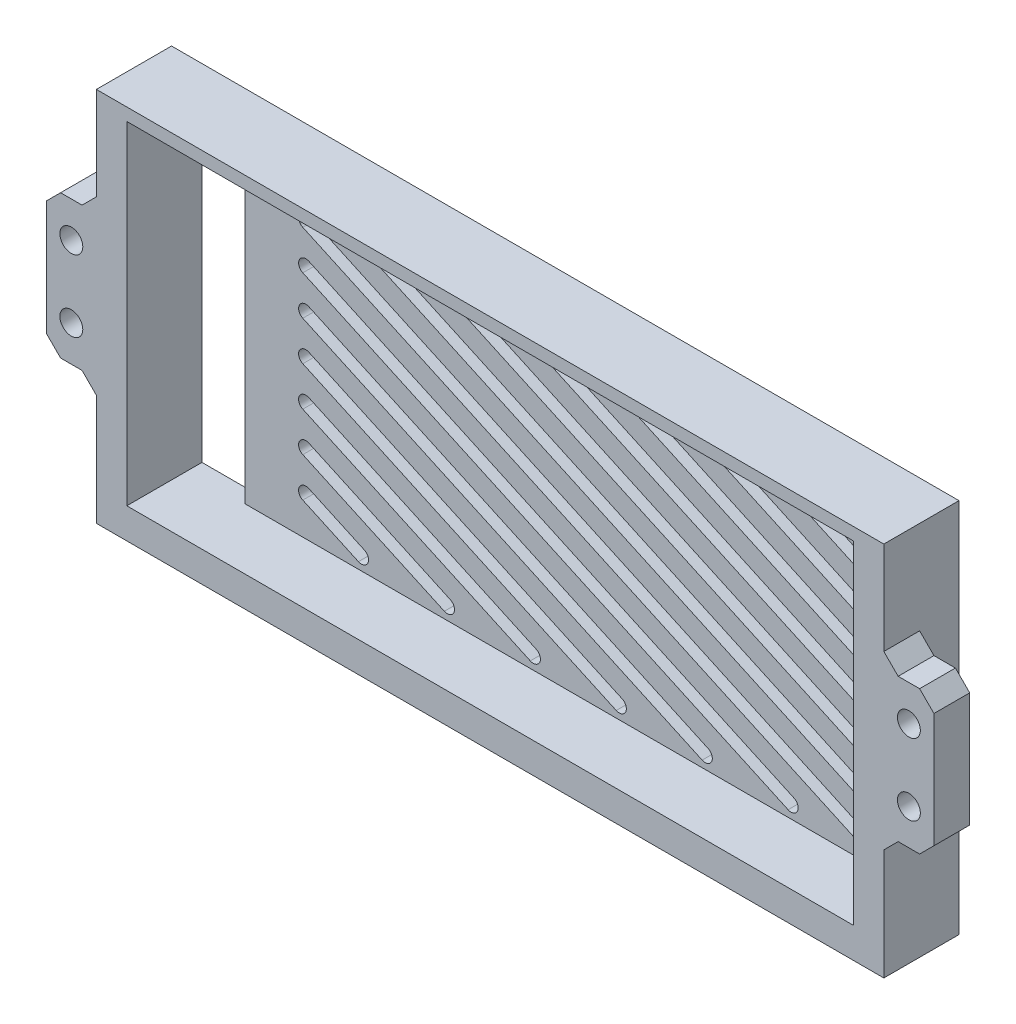
from build123d import *

# Parameters (mm, degrees)
SKETCH_1_W          = 110
SKETCH_1_H          = 52.5
EXTRUDE_1_DEPTH     = 2
SKETCH_2_W          = 110
SKETCH_2_H          = 52.5
SKETCH_2_W_2        = 101.5
SKETCH_2_H_2        = 46.5
EXTRUDE_2_DEPTH     = 8.5
CUT_EXTRUDE_1_DEPTH = 3
SKETCH_5_W          = 8
SKETCH_5_H          = 46.5
CUT_EXTRUDE_2_DEPTH = 3
SKETCH_6_W          = 7
SKETCH_6_H          = 20
SKETCH_6_R          = 1.6
EXTRUDE_3_DEPTH     = 5
CHAMFER_1_SIZE      = 2


with BuildPart() as part:
    # 草图1 → 凸台-拉伸1 (new body)
    with BuildSketch(Plane.XY):
        with Locations((55, 26.25)):
            Rectangle(SKETCH_1_W, SKETCH_1_H)
    extrude(amount=EXTRUDE_1_DEPTH)

    # 草图2 → 凸台-拉伸2 (add)
    with BuildSketch(Plane.XY.offset(2)):
        with Locations((55, 26.25)):
            Rectangle(SKETCH_2_W, SKETCH_2_H)
        with Locations((55, 27.5)):
            Rectangle(SKETCH_2_W_2, SKETCH_2_H_2, mode=Mode.SUBTRACT)
    extrude(amount=EXTRUDE_2_DEPTH)

    # 草图3 → 切除-拉伸1 (cut, through all)
    with BuildSketch(Plane.XY.offset(2)):
        with BuildLine():
            Line((21.166500495, 10.551667335), (28.937295815, 6.991647804))
            ThreePointArc((28.937295815, 6.991647804), (29.429930809, 5.66601182), (28.104294825, 5.173376826))
            Line((28.104294825, 5.173376826), (20.333499505, 8.733396357))
            ThreePointArc((20.333499505, 8.733396357), (19.840864511, 10.059032341), (21.166500495, 10.551667335))
        make_face()
        with BuildLine():
            Line((91.499535297, 49.826623174), (102.166500495, 44.939786901))
            ThreePointArc((102.166500495, 44.939786901), (102.659135489, 43.614150917), (101.333499505, 43.121515923))
            Line((101.333499505, 43.121515923), (90.666534307, 48.008352196))
            ThreePointArc((90.666534307, 48.008352196), (90.173899313, 49.33398818), (91.499535297, 49.826623174))
        make_face()
        with BuildLine():
            Line((21.166500495, 16.051397639), (40.942083467, 6.991647804))
            ThreePointArc((40.942083467, 6.991647804), (41.434718462, 5.66601182), (40.109082477, 5.173376826))
            Line((40.109082477, 5.173376826), (20.333499505, 14.233126661))
            ThreePointArc((20.333499505, 14.233126661), (19.840864511, 15.558762645), (21.166500495, 16.051397639))
        make_face()
        with BuildLine():
            Line((21.166500495, 21.551127943), (52.94687112, 6.991647804))
            ThreePointArc((52.94687112, 6.991647804), (53.439506114, 5.66601182), (52.11387013, 5.173376826))
            Line((52.11387013, 5.173376826), (20.333499505, 19.732856965))
            ThreePointArc((20.333499505, 19.732856965), (19.840864511, 21.058492949), (21.166500495, 21.551127943))
        make_face()
        with BuildLine():
            Line((21.166500495, 32.550588551), (76.956446425, 6.991647804))
            ThreePointArc((76.956446425, 6.991647804), (77.449081419, 5.66601182), (76.123445435, 5.173376826))
            Line((76.123445435, 5.173376826), (20.333499505, 30.732317572))
            ThreePointArc((20.333499505, 30.732317572), (19.840864511, 32.057953556), (21.166500495, 32.550588551))
        make_face()
        with BuildLine():
            Line((21.166500495, 27.050858247), (64.951658772, 6.991647804))
            ThreePointArc((64.951658772, 6.991647804), (65.444293766, 5.66601182), (64.118657782, 5.173376826))
            Line((64.118657782, 5.173376826), (20.333499505, 25.232587268))
            ThreePointArc((20.333499505, 25.232587268), (19.840864511, 26.558223253), (21.166500495, 27.050858247))
        make_face()
        with BuildLine():
            Line((21.166500495, 38.050318854), (88.961234077, 6.991647804))
            ThreePointArc((88.961234077, 6.991647804), (89.453869071, 5.66601182), (88.128233087, 5.173376826))
            Line((88.128233087, 5.173376826), (20.333499505, 36.232047876))
            ThreePointArc((20.333499505, 36.232047876), (19.840864511, 37.55768386), (21.166500495, 38.050318854))
        make_face()
        with BuildLine():
            Line((21.166500495, 43.550049158), (100.96602173, 6.991647804))
            ThreePointArc((100.96602173, 6.991647804), (101.458656724, 5.66601182), (100.13302074, 5.173376826))
            Line((100.13302074, 5.173376826), (20.333499505, 41.73177818))
            ThreePointArc((20.333499505, 41.73177818), (19.840864511, 43.057414164), (21.166500495, 43.550049158))
        make_face()
        with BuildLine():
            Line((21.166500495, 49.049779462), (102.166500495, 11.941405078))
            ThreePointArc((102.166500495, 11.941405078), (102.659135489, 10.615769094), (101.333499505, 10.1231341))
            Line((101.333499505, 10.1231341), (20.333499505, 47.231508484))
            ThreePointArc((20.333499505, 47.231508484), (19.840864511, 48.557144468), (21.166500495, 49.049779462))
        make_face()
        with BuildLine():
            Line((31.475597035, 49.826623174), (102.166500495, 17.441135382))
            ThreePointArc((102.166500495, 17.441135382), (102.659135489, 16.115499398), (101.333499505, 15.622864403))
            Line((101.333499505, 15.622864403), (30.642596045, 48.008352196))
            ThreePointArc((30.642596045, 48.008352196), (30.149961051, 49.33398818), (31.475597035, 49.826623174))
        make_face()
        with BuildLine():
            Line((43.480384687, 49.826623174), (102.166500495, 22.940865686))
            ThreePointArc((102.166500495, 22.940865686), (102.659135489, 21.615229701), (101.333499505, 21.122594707))
            Line((101.333499505, 21.122594707), (42.647383697, 48.008352196))
            ThreePointArc((42.647383697, 48.008352196), (42.154748703, 49.33398818), (43.480384687, 49.826623174))
        make_face()
        with BuildLine():
            Line((55.48517234, 49.826623174), (102.166500495, 28.440595989))
            ThreePointArc((102.166500495, 28.440595989), (102.659135489, 27.114960005), (101.333499505, 26.622325011))
            Line((101.333499505, 26.622325011), (54.65217135, 48.008352196))
            ThreePointArc((54.65217135, 48.008352196), (54.159536356, 49.33398818), (55.48517234, 49.826623174))
        make_face()
        with BuildLine():
            Line((67.489959992, 49.826623174), (102.166500495, 33.940326293))
            ThreePointArc((102.166500495, 33.940326293), (102.659135489, 32.614690309), (101.333499505, 32.122055315))
            Line((101.333499505, 32.122055315), (66.656959002, 48.008352196))
            ThreePointArc((66.656959002, 48.008352196), (66.164324008, 49.33398818), (67.489959992, 49.826623174))
        make_face()
        with BuildLine():
            Line((79.494747645, 49.826623174), (102.166500495, 39.440056597))
            ThreePointArc((102.166500495, 39.440056597), (102.659135489, 38.114420613), (101.333499505, 37.621785619))
            Line((101.333499505, 37.621785619), (78.661746655, 48.008352196))
            ThreePointArc((78.661746655, 48.008352196), (78.16911166, 49.33398818), (79.494747645, 49.826623174))
        make_face()
    extrude(amount=-CUT_EXTRUDE_1_DEPTH, mode=Mode.SUBTRACT)

    # 草图5 → 切除-拉伸2 (cut, through all)
    with BuildSketch(Plane.XY.offset(2)):
        with Locations((8.25, 27.5)):
            Rectangle(SKETCH_5_W, SKETCH_5_H)
    extrude(amount=-CUT_EXTRUDE_2_DEPTH, mode=Mode.SUBTRACT)

    # 草图6 → 凸台-拉伸3 (add)
    with BuildSketch(Plane.XY.offset(10.5)):
        with Locations((113.5, 27.5)):
            Rectangle(SKETCH_6_W, SKETCH_6_H)
        with Locations((113.5, 32.5)):
            Circle(SKETCH_6_R, mode=Mode.SUBTRACT)
        with Locations((113.5, 22.5)):
            Circle(SKETCH_6_R, mode=Mode.SUBTRACT)
        with Locations((-3.5, 27.5)):
            Rectangle(SKETCH_6_W, SKETCH_6_H)
        with Locations((-3.5, 22.5)):
            Circle(SKETCH_6_R, mode=Mode.SUBTRACT)
        with Locations((-3.5, 32.5)):
            Circle(SKETCH_6_R, mode=Mode.SUBTRACT)
    extrude(amount=-EXTRUDE_3_DEPTH)

    # 倒角1
    chamfer_1_edges = [part.edges().sort_by_distance(p)[0] for p in [
        (110, 17.5, 8),
        (110, 37.5, 8),
        (117, 37.5, 8),
        (117, 17.5, 8),
        (0, 37.5, 8),
        (0, 17.5, 8),
        (-7, 17.5, 8),
        (-7, 37.5, 8),
    ]]
    chamfer(chamfer_1_edges, length=CHAMFER_1_SIZE)


solid = part.part
